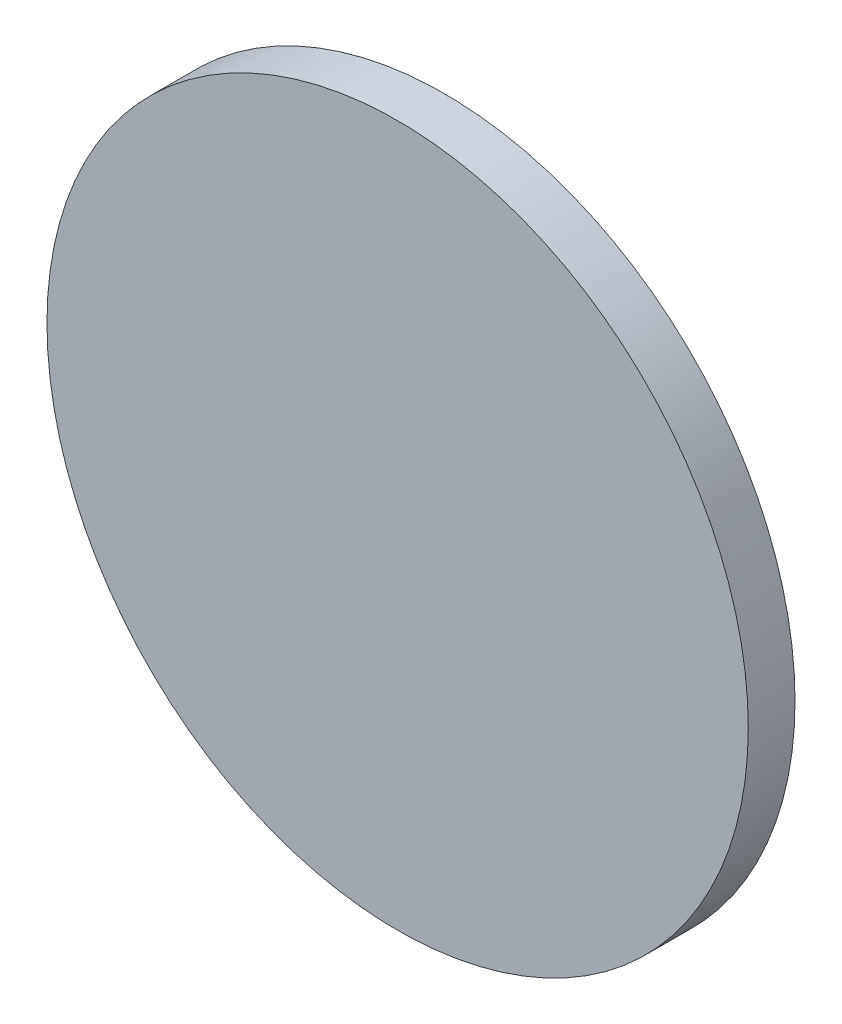
from build123d import *

# Parameters (mm, degrees)
SKETCH1_R           = 15
BOSS_EXTRUDE1_DEPTH = 2


with BuildPart() as part:
    # Sketch1 → Boss-Extrude1 (new body)
    with BuildSketch(Plane.XY):
        with Locations((475, -275)):
            Circle(SKETCH1_R)
    extrude(amount=BOSS_EXTRUDE1_DEPTH)


solid = part.part
